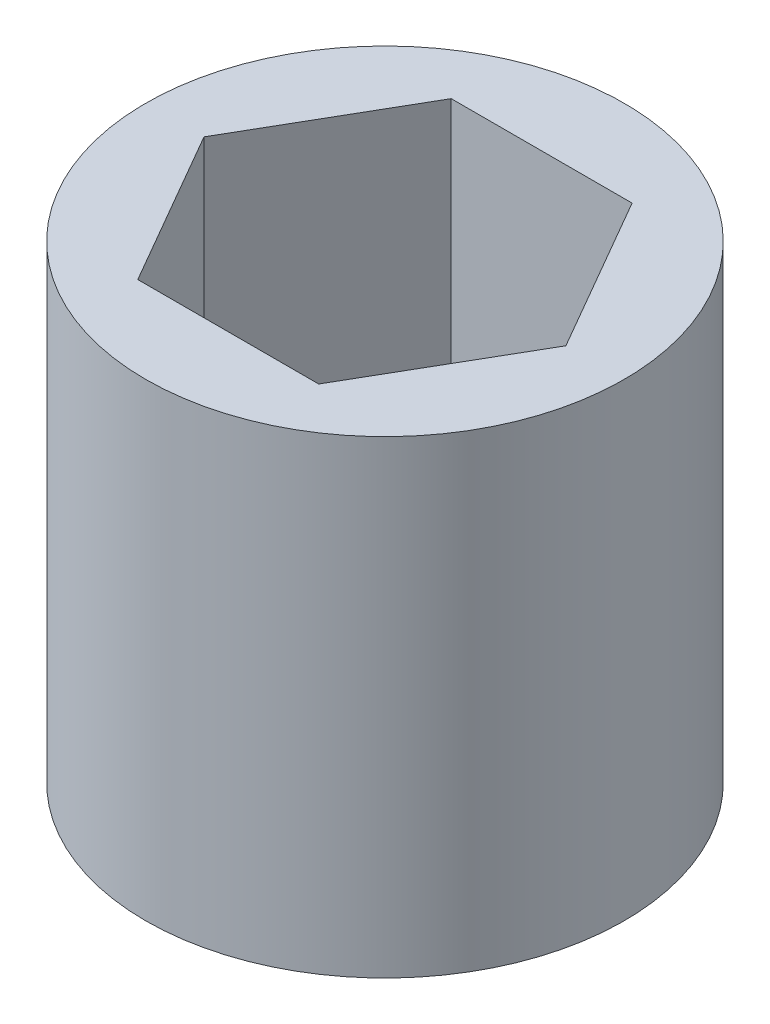
from build123d import *

# Parameters (mm, degrees)
SKETCH1_R           = 7.5
BOSS_EXTRUDE1_DEPTH = 7.35


with BuildPart() as part:
    # Sketch1 → Boss-Extrude1 (new, symmetric)
    with BuildSketch(Plane(origin=(0, 0, 0), x_dir=(1, 0, 0), z_dir=(0, 1, 0))):
        Circle(SKETCH1_R)
        Polygon((-2.836233197, -4.9125), (2.836233197, -4.9125), (5.672466395, 0), (2.836233197, 4.9125), (-2.836233197, 4.9125), (-5.672466395, 0), align=None, mode=Mode.SUBTRACT)
    extrude(amount=BOSS_EXTRUDE1_DEPTH, both=True)


solid = part.part
